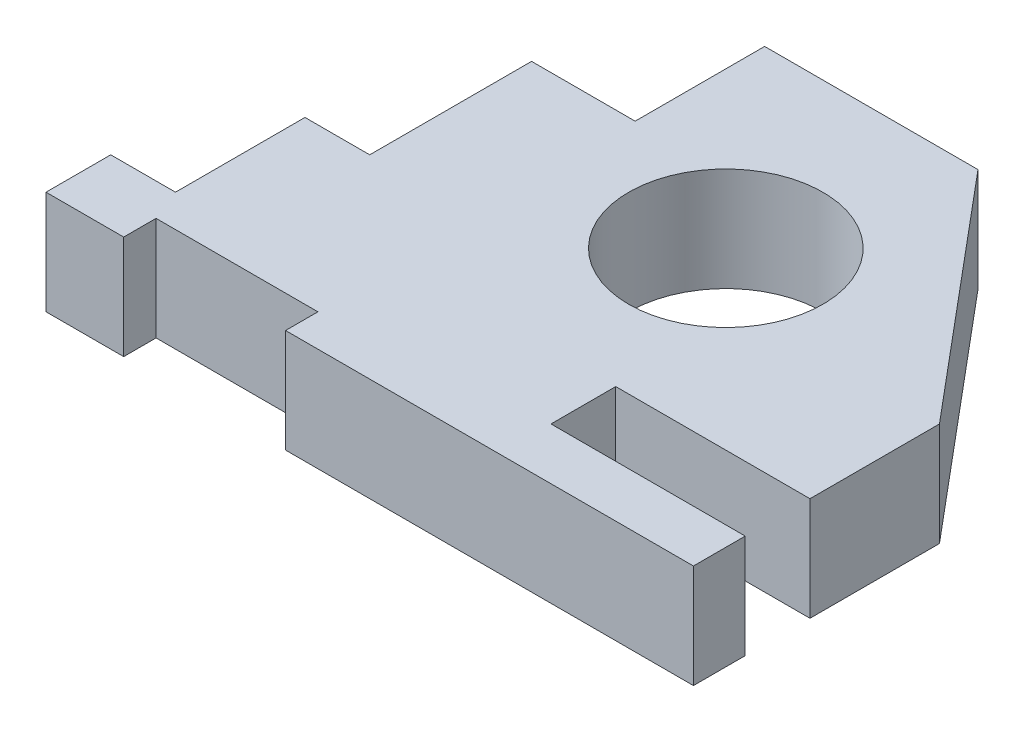
from build123d import *

# Parameters (mm, degrees)
SKETCH1_R           = 15
BOSS_EXTRUDE1_DEPTH = 16


with BuildPart() as part:
    # Sketch1 → Boss-Extrude1 (new body)
    with BuildSketch(Plane(origin=(0, 0, 0), x_dir=(1, 0, 0), z_dir=(0, 1, 0))):
        Polygon((0, 0), (12, 0), (12, 5), (37, 5), (37, 0), (100, 0), (100, 8), (70, 8), (70, 18), (100, 18), (100, 38), (68.953313646, 75), (36, 75), (36, 55), (20, 55), (20, 30), (10, 30), (10, 10), (0, 10), align=None)
        with Locations((60, 45)):
            Circle(SKETCH1_R, mode=Mode.SUBTRACT)
    extrude(amount=BOSS_EXTRUDE1_DEPTH)


solid = part.part
